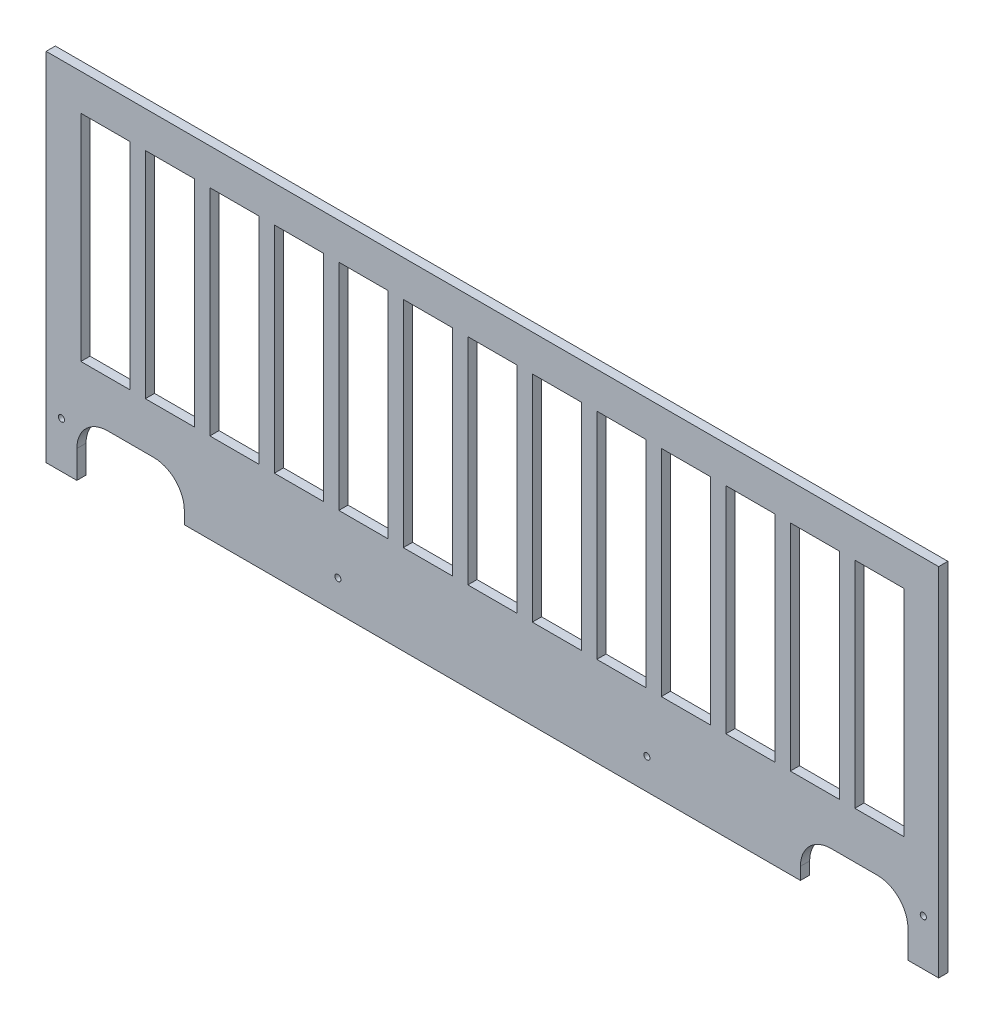
from build123d import *

# Parameters (mm, degrees)
ESQUISSE5_R      = 1
ESQUISSE5_W      = 16
ESQUISSE5_H      = 70
ESQUISSE5_W_2    = 15.999999999
EXTRUSION1_DEPTH = 3


with BuildPart() as part:
    # Esquisse5 → Extrusion1 (new body)
    with BuildSketch(Plane.XY):
        with BuildLine():
            Line((-3.928476502, 116), (286.670329677, 116))
            Line((286.670329677, 116), (286.670329677, 0))
            Line((286.670329677, 0), (276.670329677, 0))
            Line((276.670329677, 0), (276.670329677, 8.999999996))
            ThreePointArc((276.670329677, 8.999999996), (273.741442764, 16.071150589), (266.670329677, 19.000128051))
            Line((266.670329677, 19.000128051), (251.670329678, 19.000128051))
            ThreePointArc((251.670329678, 19.000128051), (244.599261866, 16.071195863), (241.670329677, 9.000128051))
            Line((241.670329677, 9.000128051), (241.670329677, 5.000128051))
            Line((241.670329677, 5.000128051), (41.070037623, 5.000128051))
            Line((41.070037623, 5.000128051), (41.070037623, 9.000128051))
            ThreePointArc((41.070037623, 9.000128051), (38.141105434, 16.071195863), (31.070037623, 19.000128051))
            Line((31.070037623, 19.000128051), (16.070037622, 19.000128051))
            ThreePointArc((16.070037622, 19.000128051), (8.998969811, 16.071195863), (6.070037623, 9.000128051))
            Line((6.070037623, 9.000128051), (6.070037623, 0))
            Line((6.070037623, 0), (-3.928476502, 0))
            Line((-3.928476502, 0), (-3.928476502, 116))
        make_face()
        with Locations((191.670329678, 14.999972575)):
            Circle(ESQUISSE5_R, mode=Mode.SUBTRACT)
        with Locations((1.071523498, 14.999972575)):
            Circle(ESQUISSE5_R, mode=Mode.SUBTRACT)
        with Locations((91.071523498, 14.999972575)):
            Circle(ESQUISSE5_R, mode=Mode.SUBTRACT)
        with Locations((281.670329677, 14.999972575)):
            Circle(ESQUISSE5_R, mode=Mode.SUBTRACT)
        Polygon((28.373009183, 104.2), (44.373009183, 104.2), (44.373009183, 34.2), (28.373009183, 34.2), align=None, mode=Mode.SUBTRACT)
        with Locations((15.373009183, 69.2)):
            Rectangle(ESQUISSE5_W, ESQUISSE5_H, mode=Mode.SUBTRACT)
        with Locations((57.373009183, 69.2)):
            Rectangle(ESQUISSE5_W, ESQUISSE5_H, mode=Mode.SUBTRACT)
        with Locations((78.373009183, 69.2)):
            Rectangle(ESQUISSE5_W, ESQUISSE5_H, mode=Mode.SUBTRACT)
        with Locations((99.373009183, 69.2)):
            Rectangle(ESQUISSE5_W, ESQUISSE5_H, mode=Mode.SUBTRACT)
        with Locations((120.373009183, 69.2)):
            Rectangle(ESQUISSE5_W, ESQUISSE5_H, mode=Mode.SUBTRACT)
        with Locations((141.373009183, 69.2)):
            Rectangle(ESQUISSE5_W, ESQUISSE5_H, mode=Mode.SUBTRACT)
        with Locations((162.373009183, 69.2)):
            Rectangle(ESQUISSE5_W_2, ESQUISSE5_H, mode=Mode.SUBTRACT)
        with Locations((183.373009182, 69.2)):
            Rectangle(ESQUISSE5_W, ESQUISSE5_H, mode=Mode.SUBTRACT)
        with Locations((204.373009182, 69.2)):
            Rectangle(ESQUISSE5_W, ESQUISSE5_H, mode=Mode.SUBTRACT)
        with Locations((225.373009182, 69.2)):
            Rectangle(ESQUISSE5_W, ESQUISSE5_H, mode=Mode.SUBTRACT)
        with Locations((246.373009182, 69.2)):
            Rectangle(ESQUISSE5_W, ESQUISSE5_H, mode=Mode.SUBTRACT)
        with Locations((267.373009182, 69.2)):
            Rectangle(ESQUISSE5_W, ESQUISSE5_H, mode=Mode.SUBTRACT)
    extrude(amount=EXTRUSION1_DEPTH)


solid = part.part
